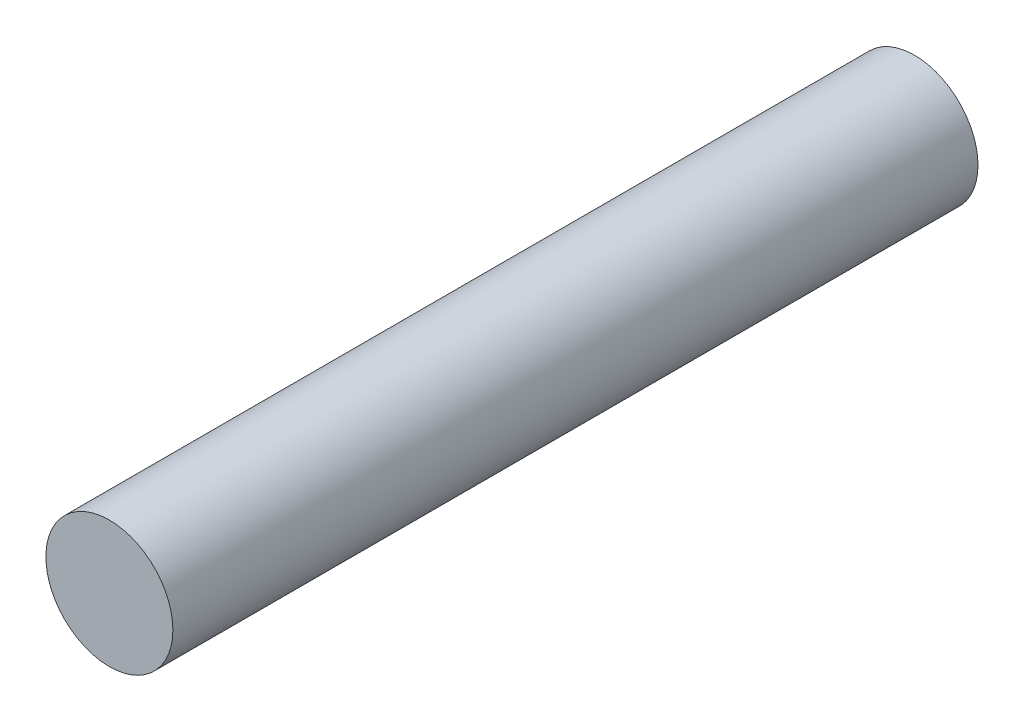
from build123d import *

# Parameters (mm, degrees)
SKETCH1_R           = 2.5
BOSS_EXTRUDE1_DEPTH = 31.7


with BuildPart() as part:
    # Sketch1 → Boss-Extrude1 (new body)
    with BuildSketch(Plane.XY):
        Circle(SKETCH1_R)
    extrude(amount=BOSS_EXTRUDE1_DEPTH)


solid = part.part
